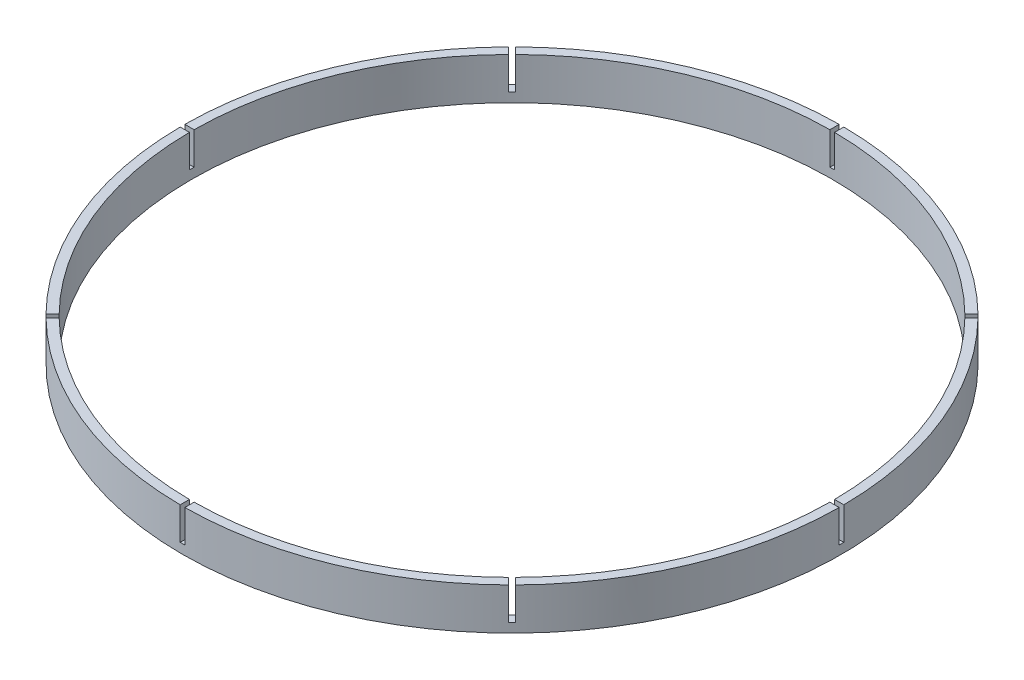
from build123d import *

# Parameters (mm, degrees)
SKETCH1_R           = 71
SKETCH1_R_2         = 69
BOSS_EXTRUDE1_DEPTH = 9
CUT_EXTRUDE1_DEPTH  = 7
CIRPATTERN1_COUNT   = 8


with BuildPart() as part:
    # Sketch1 → Boss-Extrude1 (new body)
    with BuildSketch(Plane(origin=(0, 0, 0), x_dir=(1, 0, 0), z_dir=(0, 1, 0))):
        Circle(SKETCH1_R)
        Circle(SKETCH1_R_2, mode=Mode.SUBTRACT)
    extrude(amount=BOSS_EXTRUDE1_DEPTH)

    # Sketch2 → Cut-Extrude1 (cut)
    with BuildSketch(Plane(origin=(0, 9, 0), x_dir=(1, 0, 0), z_dir=(0, 1, 0))):
        with BuildLine():
            Line((0.5, 68.998188382), (0.5, 70.998239415))
            ThreePointArc((0.5, 70.998239415), (0, 71), (-0.5, 70.998239415))
            Line((-0.5, 70.998239415), (-0.5, 68.998188382))
            ThreePointArc((-0.5, 68.998188382), (0, 69), (0.5, 68.998188382))
        make_face()
    cut_extrude1 = extrude(amount=-CUT_EXTRUDE1_DEPTH, mode=Mode.SUBTRACT)

    # CirPattern1: Cut-Extrude1 ×8 about axis
    cirpattern1_axis = Axis((0, 0, 0), (0, 1, 0))
    for i in range(1, CIRPATTERN1_COUNT):
        add(cut_extrude1.rotate(cirpattern1_axis, i * 360 / CIRPATTERN1_COUNT), mode=Mode.SUBTRACT)


solid = part.part
